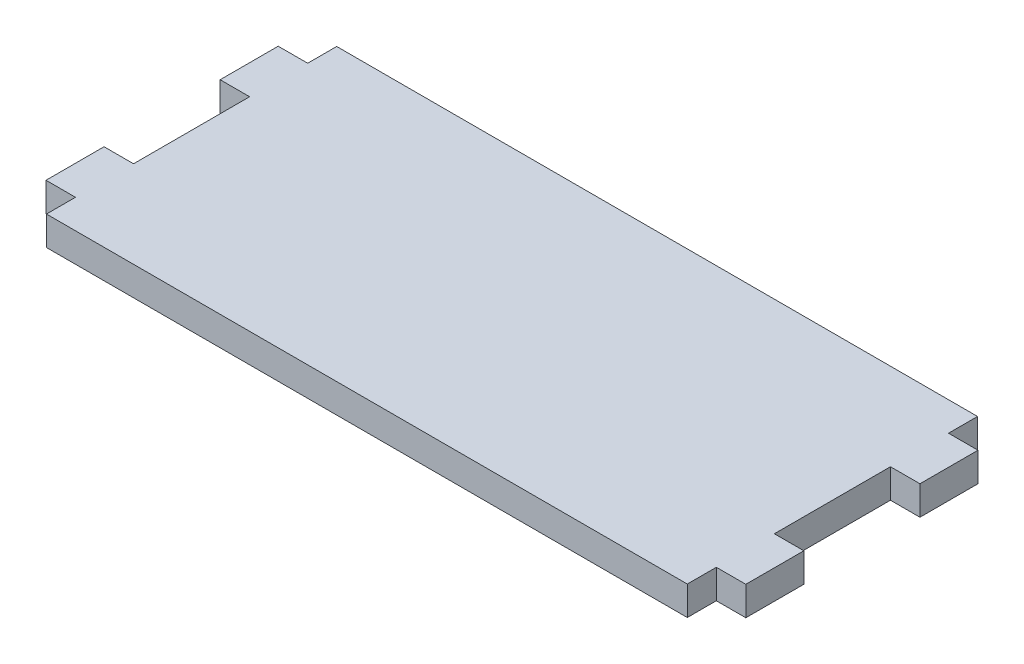
from build123d import *

# Parameters (mm, degrees)
SKETCH1_W           = 70.104
SKETCH1_H           = 31.75
BOSS_EXTRUDE1_DEPTH = 3.175
SKETCH2_W           = 3.2258
SKETCH2_H           = 6.35
TABS_DEPTH          = 3.175


with BuildPart() as part:
    # Sketch1 → Boss-Extrude1 (new body)
    with BuildSketch(Plane(origin=(0, 0, 0), x_dir=(1, 0, 0), z_dir=(0, 1, 0))):
        Rectangle(SKETCH1_W, SKETCH1_H)
    extrude(amount=BOSS_EXTRUDE1_DEPTH)

    # Sketch2 → tabs (add)
    with BuildSketch(Plane(origin=(0, 3.175, 0), x_dir=(1, 0, 0), z_dir=(0, 1, 0))):
        with Locations((-36.6649, 9.525)):
            Rectangle(SKETCH2_W, SKETCH2_H)
        with Locations((-36.6649, -9.525)):
            Rectangle(SKETCH2_W, SKETCH2_H)
    tabs = extrude(amount=-TABS_DEPTH)

    # Mirror1: tabs across plane
    add(tabs.mirror(Plane(origin=(0, 0, 0), x_dir=(0, 0, 1), z_dir=(1, 0, 0))))


solid = part.part
